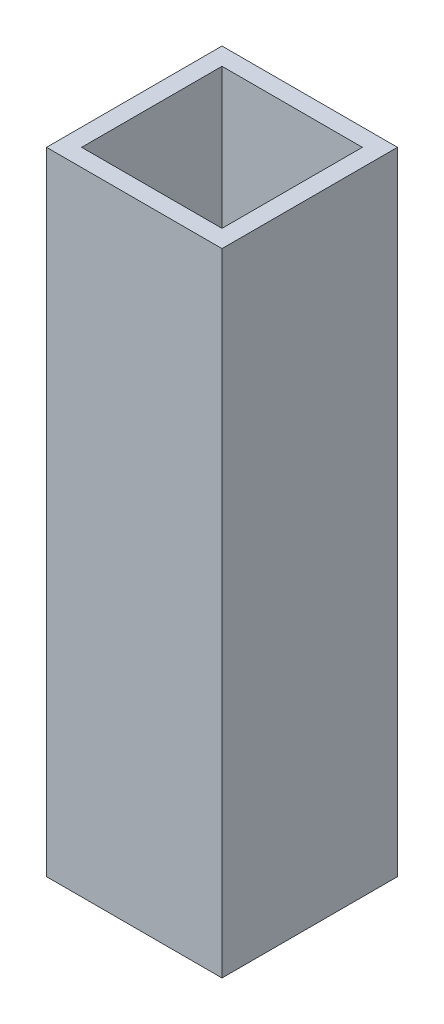
from build123d import *

# Parameters (mm, degrees)
SKETCH1_W           = 12.5
SKETCH1_H           = 12.5
BOSS_EXTRUDE1_DEPTH = 45
SKETCH2_W           = 10
SKETCH2_H           = 10
CUT_EXTRUDE1_DEPTH  = 42.5


with BuildPart() as part:
    # Sketch1 → Boss-Extrude1 (new body)
    with BuildSketch(Plane(origin=(0, 0, 0), x_dir=(1, 0, 0), z_dir=(0, 1, 0))):
        with Locations((-1.759708738, 2.912621359)):
            Rectangle(SKETCH1_W, SKETCH1_H)
    extrude(amount=BOSS_EXTRUDE1_DEPTH)

    # Sketch2 → Cut-Extrude1 (cut)
    with BuildSketch(Plane(origin=(0, 45, 0), x_dir=(1, 0, 0), z_dir=(0, 1, 0))):
        with Locations((-1.759708738, 2.912621359)):
            Rectangle(SKETCH2_W, SKETCH2_H)
    extrude(amount=-CUT_EXTRUDE1_DEPTH, mode=Mode.SUBTRACT)


solid = part.part
